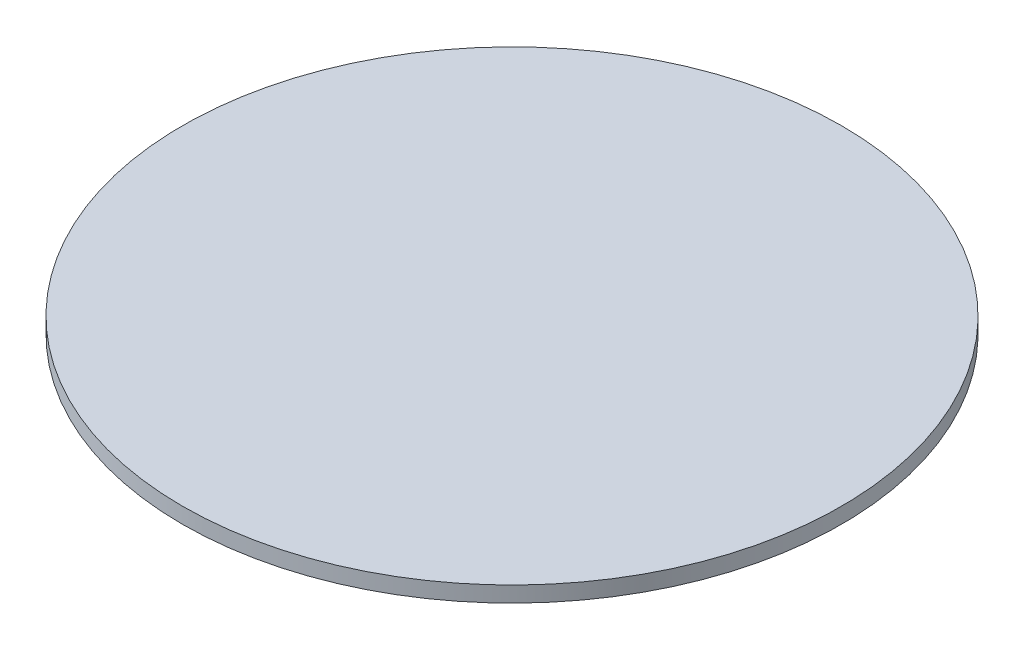
from build123d import *

# Parameters (mm, degrees)
ESBO_O1_R                = 84
RESSALTO_EXTRUS_O1_DEPTH = 4


with BuildPart() as part:
    # Esboço1 → Ressalto-extrusão1 (new body)
    with BuildSketch(Plane(origin=(0, 0, 0), x_dir=(1, 0, 0), z_dir=(0, 1, 0))):
        Circle(ESBO_O1_R)
    extrude(amount=RESSALTO_EXTRUS_O1_DEPTH)


solid = part.part
